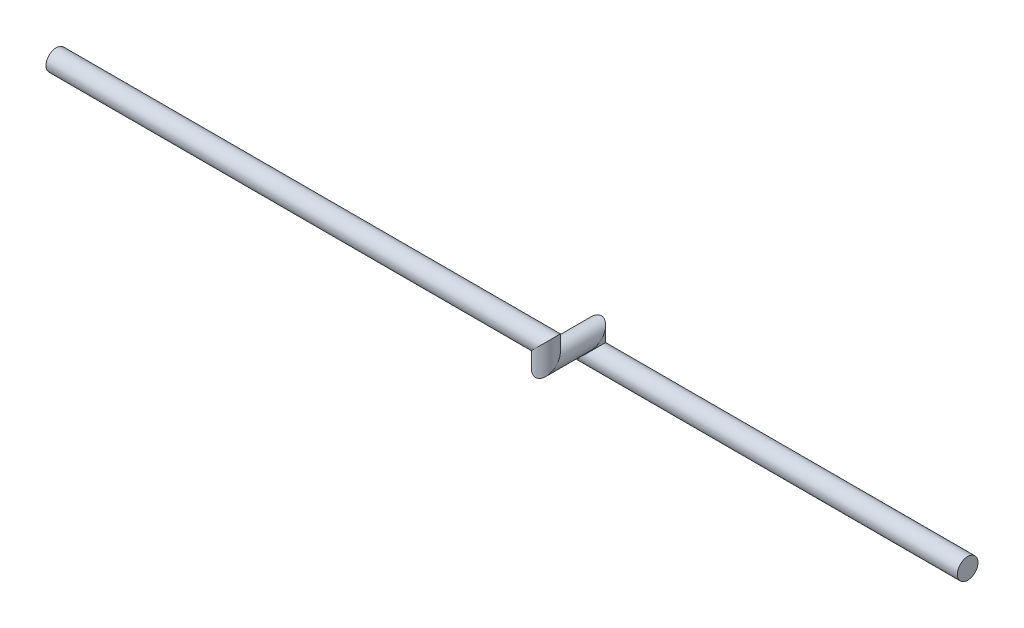
from build123d import *

# Parameters (mm, degrees)
CROQUIS1_R = 13.7


with BuildPart() as part:
    # Barrer1: sweep along a curve in space
    with BuildLine() as barrer1_path:
        Line((0, 0, 0), (-500, 0, 0))
        Line((-500, 0, 0), (-500, 20, 0))
        Line((-500, 20, 0), (-500, 20, 60))
        Line((-500, 20, 60), (-500, 40, 60))
        Line((-500, 40, 60), (-1150, 40, 60))
    # Croquis1 → Barrer1 (sweep)
    with BuildSketch(Plane(origin=(0, 0, 0), x_dir=(0, 0, -1), z_dir=(1, 0, 0))):
        Circle(CROQUIS1_R)
    sweep(path=barrer1_path.line, transition=Transition.RIGHT)


solid = part.part
